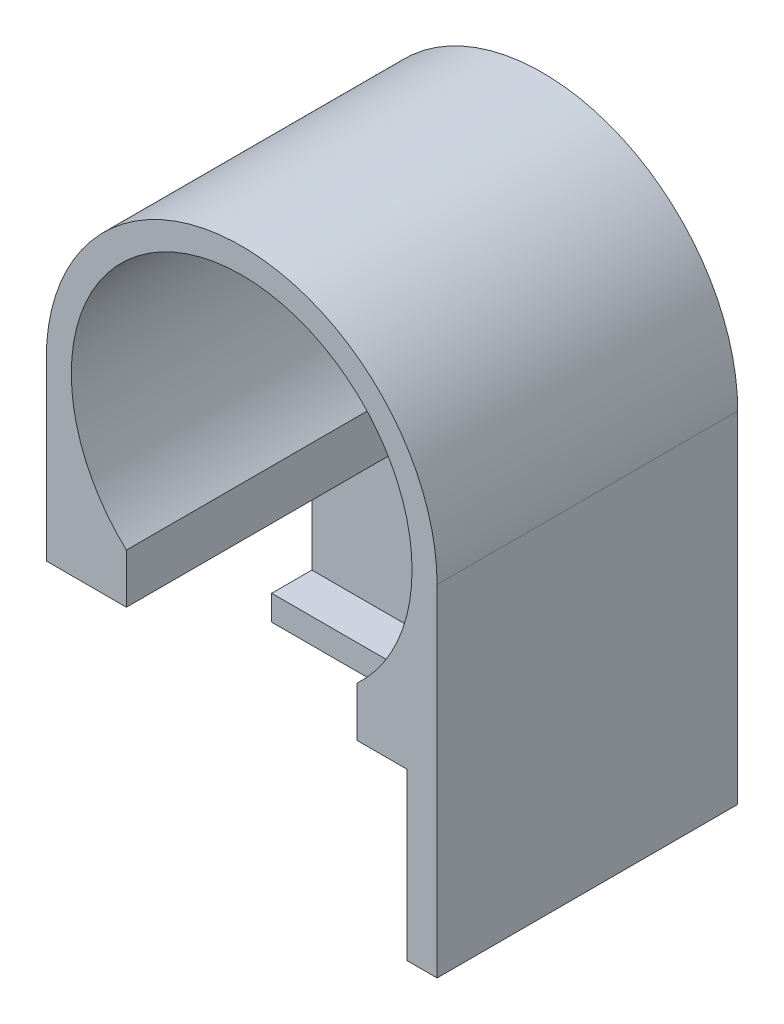
from build123d import *

# Parameters (mm, degrees)
SKETCH1_R               = 49.53
SKETCH1_R_2             = 43.18
BOSS_EXTRUDE1_DEPTH     = 76.2
BOSS_EXTRUDE2_DEPTH     = 76.2
CUT_EXTRUDE4_DEPTH      = 91.44
CUT_EXTRUDE5_DEPTH      = 20.066
CUT_EXTRUDE5_DEPTH_BACK = 23.622


with BuildPart() as part:
    # Sketch1 → Boss-Extrude1 (new body)
    with BuildSketch(Plane.XY):
        Circle(SKETCH1_R)
        Circle(SKETCH1_R_2, mode=Mode.SUBTRACT)
    extrude(amount=BOSS_EXTRUDE1_DEPTH)

    # Sketch2 → Boss-Extrude2 (add)
    with BuildSketch(Plane.XY):
        with BuildLine():
            ThreePointArc((49.53, 0), (0, -49.53), (-49.53, 0))
            Line((-49.53, 0), (-49.53, -49.53))
            Line((-49.53, -49.53), (-49.53, -86.36))
            Line((-49.53, -86.36), (0, -86.36))
            Line((0, -86.36), (49.53, -86.36))
            Line((49.53, -86.36), (49.53, 0))
        make_face()
    extrude(amount=BOSS_EXTRUDE2_DEPTH)

    # Sketch3 → Cut-Extrude4 (cut)
    with BuildSketch(Plane.ZY.offset(49.53)):
        Polygon((19.065134697, -80.01), (19.065134697, -86.36), (31.768891325, -86.36), (76.2, -86.36), (76.2, -44.356391486), (8.879845192, -44.356391486), (8.879845192, -80.01), align=None)
    extrude(amount=-CUT_EXTRUDE4_DEPTH, mode=Mode.SUBTRACT)

    # Sketch6 → Cut-Extrude5 (cut, two sides)
    with BuildSketch(Plane.XZ.offset(44.356391486)) as cut_extrude5_sk:
        Polygon((0, 76.2), (-29.21, 76.2), (-29.21, 8.879845192), (29.21, 8.879845192), (29.21, 76.2), align=None)
    extrude(amount=CUT_EXTRUDE5_DEPTH, mode=Mode.SUBTRACT)
    extrude(cut_extrude5_sk.sketch, amount=-CUT_EXTRUDE5_DEPTH_BACK, mode=Mode.SUBTRACT)


solid = part.part
